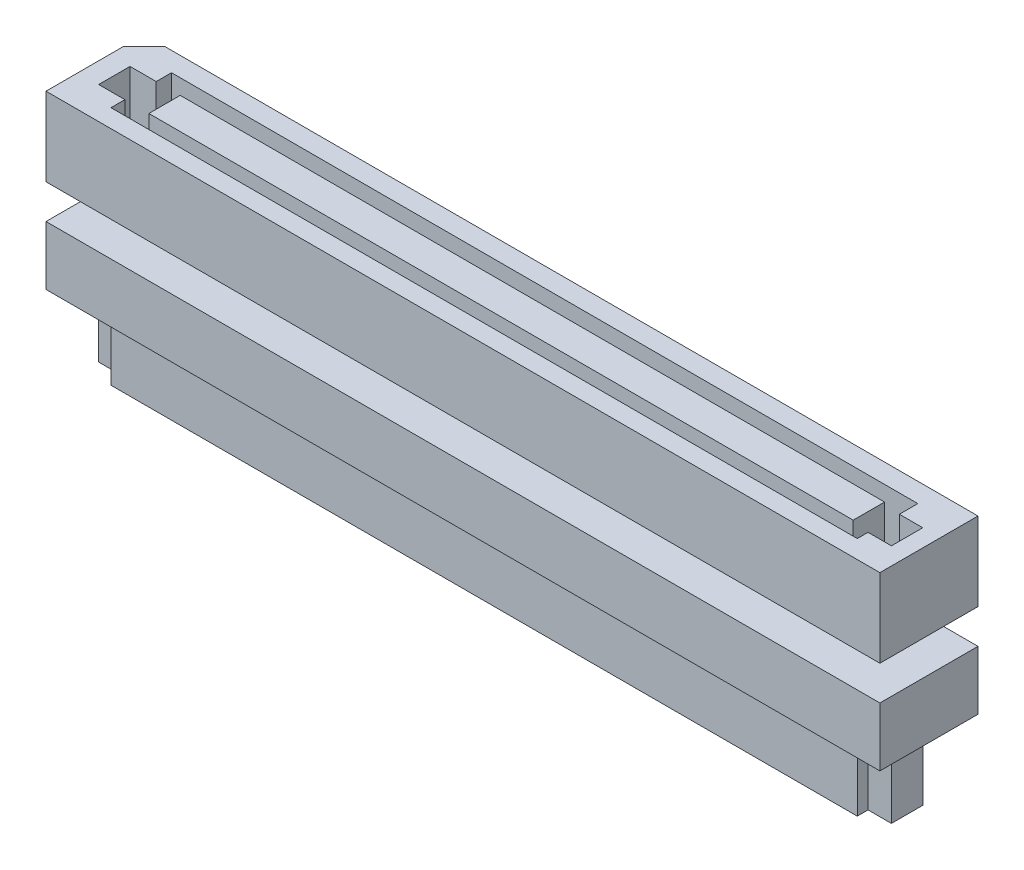
from build123d import *

# Parameters (mm, degrees)
SV_DEPTH           = 4
SKETCH3_W          = 35.897762959
SKETCH3_H          = 1.597828601
CUT_EXTRUDE1_DEPTH = 3.5
SV2_A_DEPTH        = 3
SKETCH7_W          = 35.897762959
SKETCH7_H          = 1.597828601
SV2_B_DEPTH        = 3.5


with BuildPart() as part:
    # Sketch1 → SV (new body)
    with BuildSketch(Plane(origin=(0, 0, 0), x_dir=(1, 0, 0), z_dir=(0, 1, 0))):
        Polygon((-20.189, 2.5), (21.25, 2.5), (21.25, -1.44), (21.25, -2.5), (20.19, -2.5), (-21.25, -2.5), (-21.25, 1.439), align=None)
    extrude(amount=SV_DEPTH)

    # Sketch3 → Cut-Extrude1 (cut)
    with BuildSketch(Plane(origin=(0, 4, 0), x_dir=(1, 0, 0), z_dir=(0, 1, 0))):
        Polygon((-20.202517392, 0.734832739), (-18.867516597, 0.734832739), (-18.867516597, 1.51327079), (19.169882457, 1.51327079), (19.169882457, 0.573528463), (20.36118295, 0.573528463), (20.36118295, -1.024300139), (19.169882457, -1.024300139), (19.169882457, -1.572342426), (-18.867516597, -1.572342426), (-18.867516597, -0.862995862), (-20.202517392, -0.862995862), align=None)
        with Locations((0.304154287, -0.064081561)):
            Rectangle(SKETCH3_W, SKETCH3_H, mode=Mode.SUBTRACT)
    extrude(amount=-CUT_EXTRUDE1_DEPTH, mode=Mode.SUBTRACT)


with BuildPart() as body_2:
    # Sketch6 → SV2(a) (new body)
    with BuildSketch(Plane(origin=(0, -1.7526, 0), x_dir=(1, 0, 0), z_dir=(0, 1, 0))):
        Polygon((21.25, -1.43808395), (21.25, -2.5), (20.18808395, -2.5), (-21.25, -2.5), (-21.25, 1.44), (-20.19, 2.5), (21.25, 2.5), align=None)
    extrude(amount=-SV2_A_DEPTH)

    # Sketch7 → SV2(b) (add)
    with BuildSketch(Plane.XZ.offset(4.7526)):
        Polygon((-18.867516597, -1.51327079), (-18.867516597, -0.734832739), (-20.202517392, -0.734832739), (-20.202517392, 0.862995862), (-18.867516597, 0.862995862), (-18.867516597, 1.572342426), (19.169882457, 1.572342426), (19.169882457, 1.024300139), (20.36118295, 1.024300139), (20.36118295, -0.573528463), (19.169882457, -0.573528463), (19.169882457, -1.51327079), align=None)
        with Locations((0.304154287, 0.064081561)):
            Rectangle(SKETCH7_W, SKETCH7_H, mode=Mode.SUBTRACT)
    extrude(amount=SV2_B_DEPTH)


solid = Compound([part.part, body_2.part])
